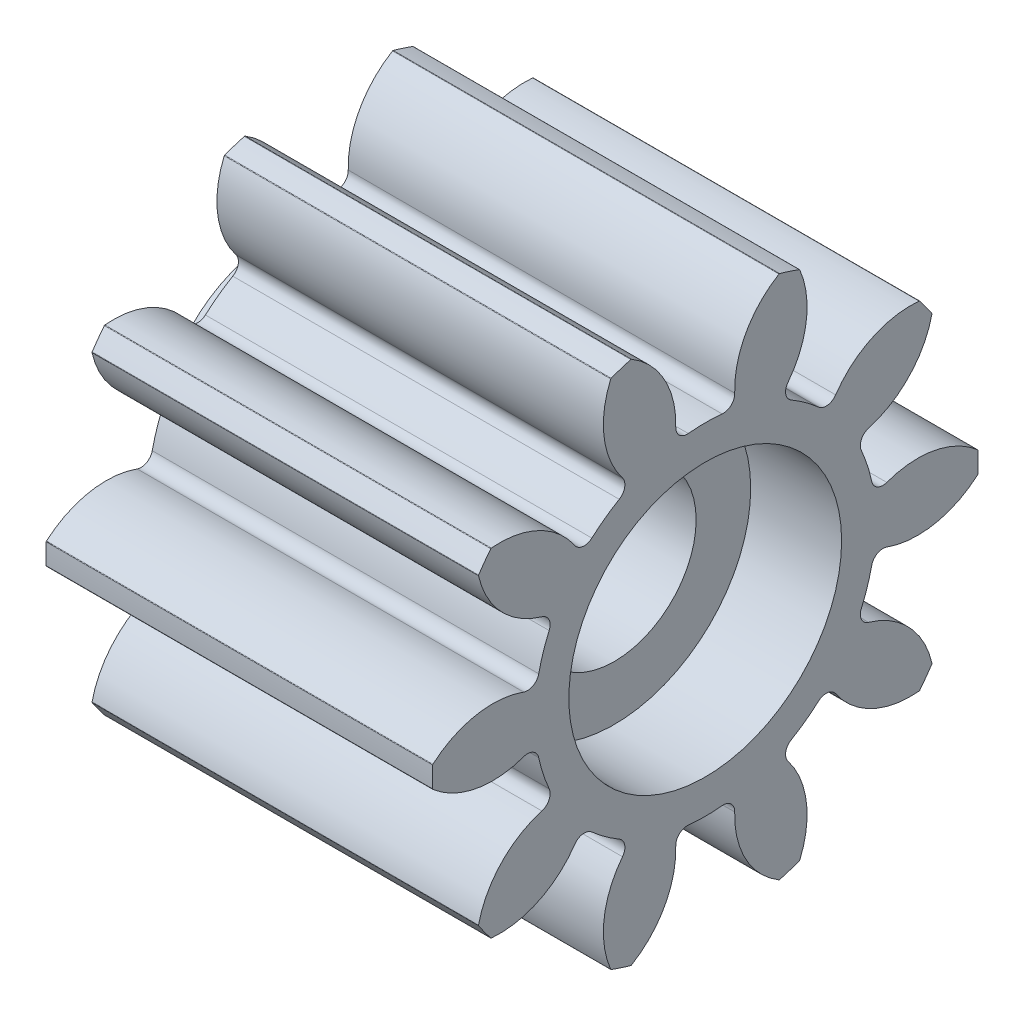
from build123d import *

# Parameters (mm, degrees)
BASPROSKE_W                = 8.5
BASPROSKE_H                = 6
TOOTHCUT_DEPTH             = 13.010412149
BREAKS_R                   = 0.02
ROOTFILLETS_R              = 0.251
TEETHCUTS_COUNT            = 10
TEETHCUTS_ANGLE            = 324
BREAKS_OF_TEETHCUTS_R      = 0.02
ROOTFILLETS_OF_TEETHCUTS_R = 0.251
BORSKE_R                   = 1.8
BORE_DEPTH                 = 50.0000508
SKETCH3_R                  = 2.5
SKETCH3_R_2                = 1.8
BOSS_EXTRUDE1_DEPTH        = 1
SKETCH4_R                  = 3
CUT_EXTRUDE2_DEPTH         = 2


with BuildPart() as part:
    # BasProSke → Base-Revolve (revolve)
    with BuildSketch(Plane(origin=(0, 0, 0), x_dir=(1, 0, 0), z_dir=(0, 1, 0)), mode=Mode.PRIVATE) as base_revolve_sk:
        with Locations((4.25, 3)):
            Rectangle(BASPROSKE_W, BASPROSKE_H)
    revolve(base_revolve_sk.sketch.rotate(Axis((-10, 0, 0), (1, 0, 0)), 180), axis=Axis((-10, 0, 0), (1, 0, 0)))

    # TooCutSke → ToothCut (cut, through all)
    with BuildSketch(Plane(origin=(0, 0, 0), x_dir=(0, 0, -1), z_dir=(1, 0, 0))):
        with BuildLine():
            ThreePointArc((0.680948119, 3.686639481), (0, 3.749), (-0.680948119, 3.686639481))
            ThreePointArc((-0.680948119, 3.686639481), (-0.833594699, 4.896067871), (-1.659981216, 5.7922282))
            ThreePointArc((-1.659981216, 5.7922282), (0, 6.0254), (1.659981216, 5.7922282))
            ThreePointArc((1.659981216, 5.7922282), (0.833594699, 4.896067871), (0.680948119, 3.686639481))
        make_face()
    toothcut = extrude(amount=TOOTHCUT_DEPTH, mode=Mode.SUBTRACT)

    # Breaks
    breaks_edges = [part.edges().sort_by_distance(p)[0] for p in [
        (4.25, 5.774516397, -1.629404918),
        (4.25, 5.774516397, 1.629404918),
    ]]
    fillet(breaks_edges, radius=BREAKS_R)

    # RootFillets
    rootfillets_edges = [part.edges().sort_by_distance(p)[0] for p in [
        (4.25, 3.686639481, -0.680948119),
        (4.25, 3.686639481, 0.680948119),
    ]]
    fillet(rootfillets_edges, radius=ROOTFILLETS_R)

    # TeethCuts: ToothCut ×10 about axis
    teethcuts_axis = Axis((-10, 0, 0), (1, 0, 0))
    for i in range(1, TEETHCUTS_COUNT):
        add(toothcut.rotate(teethcuts_axis, i * TEETHCUTS_ANGLE / (TEETHCUTS_COUNT - 1)), mode=Mode.SUBTRACT)

    # Breaks of TeethCuts
    breaks_of_teethcuts_edges = [part.edges().sort_by_distance(p)[0] for p in [
        (4.25, 5.62942208, 2.075959308),
        (4.25, 3.713941719, 4.712391846),
        (4.25, 3.334079865, 4.988377637),
        (4.25, 0.234767536, 5.995405258),
        (4.25, -0.234767536, 5.995405258),
        (4.25, -3.334079865, 4.988377637),
        (4.25, -3.713941719, 4.712391846),
        (4.25, -5.62942208, 2.075959308),
        (4.25, -5.774516397, 1.629404918),
        (4.25, -5.774516397, -1.629404918),
        (4.25, -5.62942208, -2.075959308),
        (4.25, -3.713941719, -4.712391846),
        (4.25, -3.334079865, -4.988377637),
        (4.25, -0.234767536, -5.995405258),
        (4.25, 0.234767536, -5.995405258),
        (4.25, 3.334079865, -4.988377637),
        (4.25, 3.713941719, -4.712391846),
        (4.25, 5.62942208, -2.075959308),
    ]]
    fillet(breaks_of_teethcuts_edges, radius=BREAKS_OF_TEETHCUTS_R)

    # RootFillets of TeethCuts
    rootfillets_of_teethcuts_edges = [part.edges().sort_by_distance(p)[0] for p in [
        (4.25, 3.382805254, 1.616053717),
        (4.25, 2.58230273, 2.717850918),
        (4.25, 1.786854397, 3.29577796),
        (4.25, 0.491614106, 3.716627042),
        (4.25, -0.491614106, 3.716627042),
        (4.25, -1.786854397, 3.29577796),
        (4.25, -2.58230273, 2.717850918),
        (4.25, -3.382805254, 1.616053717),
        (4.25, -3.686639481, 0.680948119),
        (4.25, -3.686639481, -0.680948119),
        (4.25, -3.382805254, -1.616053717),
        (4.25, -2.58230273, -2.717850918),
        (4.25, -1.786854397, -3.29577796),
        (4.25, -0.491614106, -3.716627042),
        (4.25, 0.491614106, -3.716627042),
        (4.25, 1.786854397, -3.29577796),
        (4.25, 2.58230273, -2.717850918),
        (4.25, 3.382805254, -1.616053717),
    ]]
    fillet(rootfillets_of_teethcuts_edges, radius=ROOTFILLETS_OF_TEETHCUTS_R)

    # BorSke → Bore (cut, symmetric)
    with BuildSketch(Plane(origin=(0, 0, 0), x_dir=(0, 0, -1), z_dir=(1, 0, 0))):
        with Locations(Location((0, 0, 0), (0, 0, 180))):
            Circle(BORSKE_R)
    extrude(amount=BORE_DEPTH, both=True, mode=Mode.SUBTRACT)

    # Sketch3 → Boss-Extrude1 (add)
    with BuildSketch(Plane.ZY):
        with Locations(Location((0, 0, 0), (0, 0, 180))):
            Circle(SKETCH3_R)
        Circle(SKETCH3_R_2, mode=Mode.SUBTRACT)
    extrude(amount=BOSS_EXTRUDE1_DEPTH)

    # Sketch4 → Cut-Extrude2 (cut)
    with BuildSketch(Plane(origin=(8.5, 0, 0), x_dir=(0, 0, -1), z_dir=(1, 0, 0))):
        Circle(SKETCH4_R)
    extrude(amount=-CUT_EXTRUDE2_DEPTH, mode=Mode.SUBTRACT)


solid = part.part
